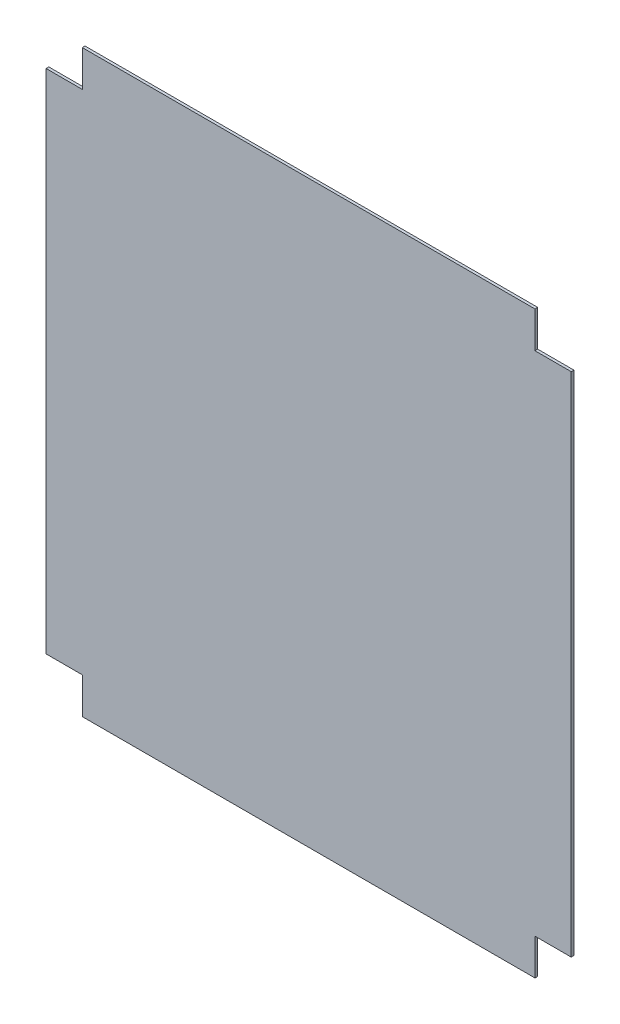
from build123d import *

# Parameters (mm, degrees)
BOSS_EXTRU_1_DEPTH = 3


with BuildPart() as part:
    # Esquisse1 → Boss.-Extru.1 (new body)
    with BuildSketch(Plane.XY):
        Polygon((-240, -250), (260, -250), (260, -210), (300, -210), (300, 350), (260, 350), (260, 390), (-240, 390), (-240, 350), (-280, 350), (-280, -210), (-240, -210), align=None)
    extrude(amount=BOSS_EXTRU_1_DEPTH)


solid = part.part
